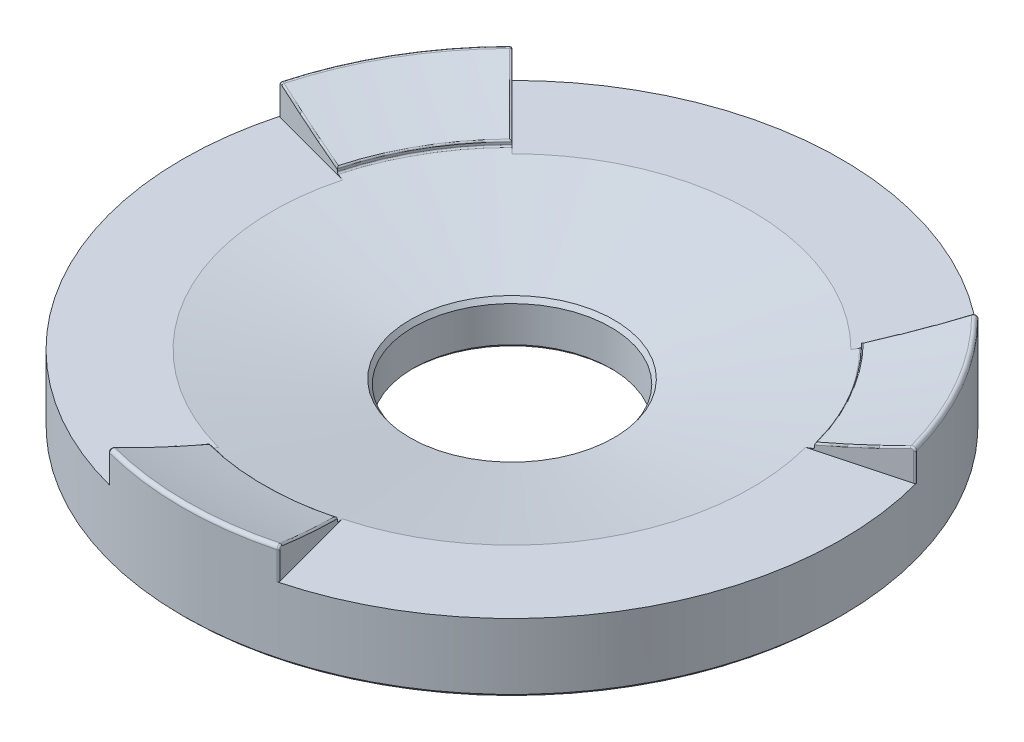
from build123d import *

# Parameters (mm, degrees)
FILLET1_R            = 0.254
CHAMFER1_SIZE        = 0.316813131
CHAMFER1_SIZE2       = 0.254
CHAMFER1_EDGE_2_SIZE = 0.254
CHAMFER1_EDGE_3_SIZE = 0.254
EXTRUDE1_DEPTH       = 71.628
CIRPATTERN1_COUNT    = 3
FILLET4_R            = 0.127


with BuildPart() as part:
    # Sketch1 → Revolve1 (revolve)
    with BuildSketch(Plane.XY, mode=Mode.PRIVATE) as revolve1_sk:
        with BuildLine():
            Line((7.62, -76.9493), (25.4, -76.9493))
            Line((25.4, -76.9493), (25.4, -69.128610555))
            ThreePointArc((25.4, -69.128610555), (16.638231697, -71.743250855), (7.62, -73.2520334))
            Line((7.62, -73.2520334), (7.62, -76.9493))
        make_face()
    revolve(revolve1_sk.sketch.rotate(Axis((0, 0, 0), (0, -1, 0)), 180), axis=Axis((0, 0, 0), (0, -1, 0)))  # turned: the seam where the file's is

    # Sketch4 → Cut-Revolve2 (revolve, cut)
    with BuildSketch(Plane.XY, mode=Mode.PRIVATE) as cut_revolve2_sk:
        with BuildLine():
            Line((7.62, -73.2520334), (7.62, -73.6330334))
            Line((7.62, -73.6330334), (19.05, -71.52186236))
            Line((19.05, -71.52186236), (19.05, -71.14086236))
            ThreePointArc((19.05, -71.14086236), (13.376714312, -72.422291537), (7.62, -73.2520334))
        make_face()
    revolve(cut_revolve2_sk.sketch.rotate(Axis((0, 0, 0), (0, -1, 0)), 90), axis=Axis((0, 0, 0), (0, -1, 0)), mode=Mode.SUBTRACT)  # turned: the seam where the file's is

    # Fillet1
    fillet1_edges = [part.edges().sort_by_distance(p)[0] for p in [
        (25.4, -69.128610555, 0),
    ]]
    fillet(fillet1_edges, radius=FILLET1_R)

    # Chamfer1
    chamfer1_edges = [part.edges().sort_by_distance(p)[0] for p in [
        (-5.388153673, -73.6330334, 5.388153673),
    ]]
    chamfer1_side = [part.faces().sort_by_distance(p)[0] for p in [
        (7.62, -75.2911667, 0),
    ]]
    chamfer(chamfer1_edges, length=CHAMFER1_SIZE, length2=CHAMFER1_SIZE2, reference=chamfer1_side[0])

    # Chamfer1 edge 2
    chamfer1_edge_2_edges = [part.edges().sort_by_distance(p)[0] for p in [
        (25.4, -76.9493, 0),
    ]]
    chamfer(chamfer1_edge_2_edges, length=CHAMFER1_EDGE_2_SIZE)

    # Chamfer1 edge 3
    chamfer1_edge_3_edges = [part.edges().sort_by_distance(p)[0] for p in [
        (7.62, -76.9493, 0),
    ]]
    chamfer(chamfer1_edge_3_edges, length=CHAMFER1_EDGE_3_SIZE)

    # Sketch5 → Extrude1 (cut)
    with BuildSketch(Plane(origin=(0, 0, 0), x_dir=(1, 0, 0), z_dir=(0, 1, 0))):
        Polygon((-27.94, 27.94), (27.94, 27.94), (0, 0), align=None)
    extrude1 = extrude(amount=-EXTRUDE1_DEPTH, mode=Mode.SUBTRACT)

    # CirPattern1: Extrude1 ×3 about axis
    cirpattern1_axis = Axis((0, 0, 0), (0, 1, 0))
    for i in range(1, CIRPATTERN1_COUNT):
        add(extrude1.rotate(cirpattern1_axis, i * 360 / CIRPATTERN1_COUNT), mode=Mode.SUBTRACT)

    # Fillet4
    fillet4_edges = [part.edges().sort_by_distance(p)[0] for p in [
        (17.884061779, -69.283659675, -17.884061779),
        (-17.884058793, -69.283659675, -17.884058793),
        (-16.497783942, -71.14086236, -9.525),
        (-16.497783942, -71.52186236, -9.525),
        (-15.609369783, -70.261084159, -15.609369783),
        (-17.960512242, -70.559793782, -17.960512242),
        (17.960512242, -70.559793782, -17.960512242),
        (15.609369783, -70.261084159, -15.609369783),
        (-24.430076308, -69.283659675, -6.546019218),
        (-6.546022021, -69.283659675, 24.430086771),
        (0, -71.14086236, 19.05),
        (2.486523962, -71.52186236, 18.887024609),
        (-5.713425878, -70.261084159, 21.32279566),
        (-6.574003746, -70.559793482, 24.534515988),
        (-24.534515988, -70.559793482, -6.574003746),
        (-21.32279566, -70.261084159, -5.713425878),
        (16.497783942, -71.52186236, -9.525),
        (16.497783942, -71.14086236, -9.525),
        (24.534515988, -70.559793182, -6.574003746),
        (21.32279566, -70.261084159, -5.713425878),
        (6.574003746, -70.559793182, 24.534515988),
        (5.713425878, -70.261084159, 21.32279566),
        (24.430078571, -69.283659675, -6.546019824),
        (6.546020368, -69.283659675, 24.4300806),
    ]]
    fillet(fillet4_edges, radius=FILLET4_R)


solid = part.part
